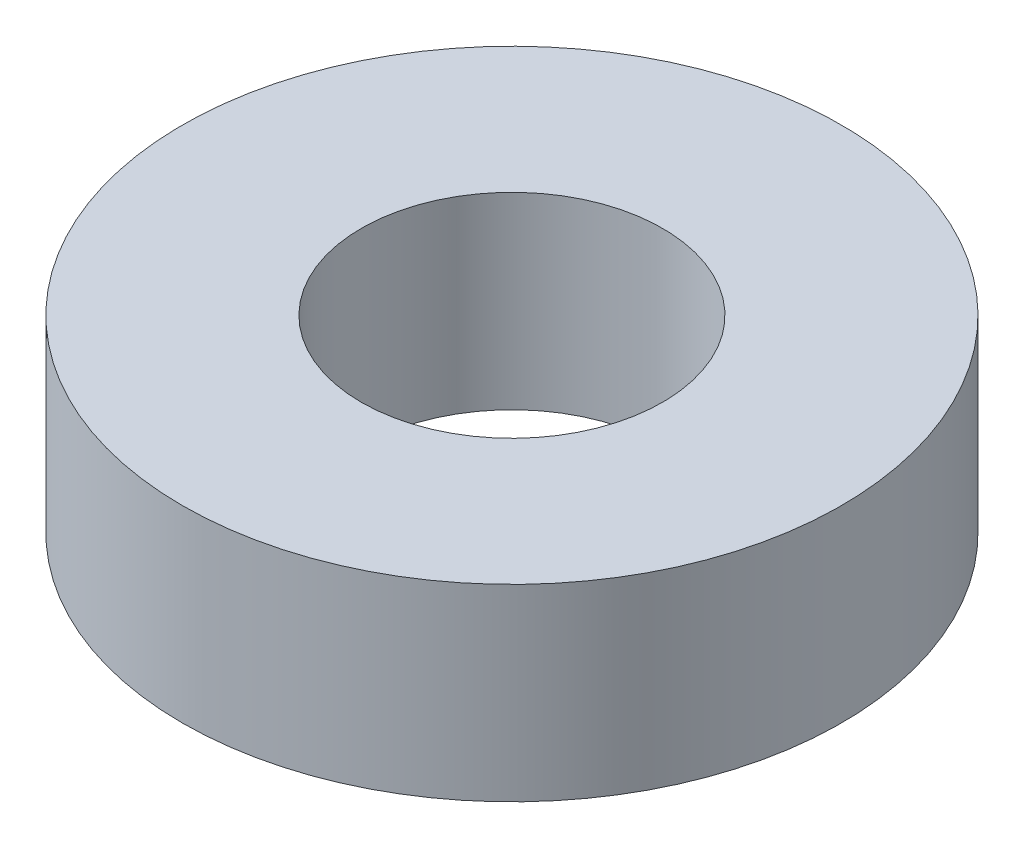
from build123d import *

# Parameters (mm, degrees)
SKETCH3_R           = 3.5
SKETCH3_R_2         = 1.6
BOSS_EXTRUDE1_DEPTH = 2


with BuildPart() as part:
    # Sketch3 → Boss-Extrude1 (new body)
    with BuildSketch(Plane(origin=(0, 0, 0), x_dir=(1, 0, 0), z_dir=(0, 1, 0))):
        Circle(SKETCH3_R)
        Circle(SKETCH3_R_2, mode=Mode.SUBTRACT)
    extrude(amount=BOSS_EXTRUDE1_DEPTH)


solid = part.part
